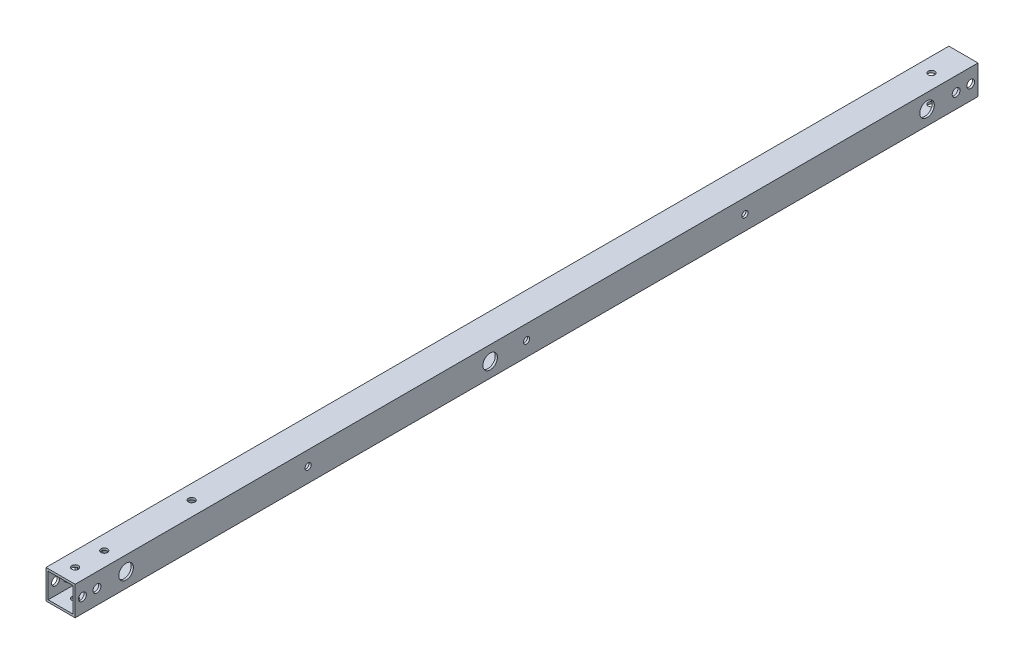
from build123d import *

# Parameters (mm, degrees)
SKETCH_1_W                  = 20
SKETCH_1_H                  = 20
SKETCH_1_W_2                = 17
SKETCH_1_H_2                = 17
EXTRUDE_1_DEPTH             = 620
SKETCH_2_R                  = 2.7
CUT_EXTRUDE_1_DEPTH         = 25
SKETCH_3_R                  = 2.25
CUT_EXTRUDE_2_DEPTH         = 25
SKETCH_4_R                  = 2.7
CUT_EXTRUDE_3_DEPTH         = 40
SKETCH_6_R                  = 5
CUT_EXTRUDE_4_DEPTH         = 10
CUT_EXTRUDE_START           = 10
SKETCH_7_R                  = 5
CUT_EXTRUDE_5_DEPTH         = 20
CUT_EXTRUDE_START_2         = -10
SKETCH_8_R                  = 5
CUT_EXTRUDE_6_DEPTH         = 30
SKETCH_9_R                  = 5
CUT_EXTRUDE_7_DEPTH         = 5
HOLE_WIZARD_4_3_4_3_1_D     = 4.3
HOLE_WIZARD_10_0_10_1_D     = 10
HOLE_WIZARD_10_0_10_1_DEPTH = 1.5


with BuildPart() as part:
    # ｽｹｯﾁ1 → ﾎﾞｽ - 押し出し1 (new body)
    with BuildSketch(Plane.XY):
        Rectangle(SKETCH_1_W, SKETCH_1_H)
        Rectangle(SKETCH_1_W_2, SKETCH_1_H_2, mode=Mode.SUBTRACT)
    extrude(amount=EXTRUDE_1_DEPTH)

    # ｽｹｯﾁ2 → ｶｯﾄ - 押し出し1 (cut)
    with BuildSketch(Plane(origin=(10, 0, 0), x_dir=(0, 0, -1), z_dir=(1, 0, 0))):
        with Locations((-585, 0)):
            Circle(SKETCH_2_R)
        with Locations((-35, 0)):
            Circle(SKETCH_2_R)
        with Locations((-335, 0)):
            Circle(SKETCH_2_R)
    extrude(amount=-CUT_EXTRUDE_1_DEPTH, mode=Mode.SUBTRACT)

    # ｽｹｯﾁ3 → ｶｯﾄ - 押し出し2 (cut)
    with BuildSketch(Plane(origin=(0, 10, 0), x_dir=(1, 0, 0), z_dir=(0, 1, 0))):
        with Locations((0, -22)):
            Circle(SKETCH_3_R)
        with Locations((0, -610)):
            Circle(SKETCH_3_R)
        with Locations((0, -530)):
            Circle(SKETCH_3_R)
        with Locations((0, -590)):
            Circle(SKETCH_3_R)
    extrude(amount=-CUT_EXTRUDE_2_DEPTH, mode=Mode.SUBTRACT)

    # ｽｹｯﾁ4 → ｶｯﾄ - 押し出し3 (cut)
    with BuildSketch(Plane(origin=(10, 0, 0), x_dir=(0, 0, -1), z_dir=(1, 0, 0))):
        with Locations((-15, 0)):
            Circle(SKETCH_4_R)
        with Locations((-5, 0)):
            Circle(SKETCH_4_R)
        with Locations((-615, 0)):
            Circle(SKETCH_4_R)
        with Locations((-605, 0)):
            Circle(SKETCH_4_R)
    extrude(amount=-CUT_EXTRUDE_3_DEPTH, mode=Mode.SUBTRACT)

    # ｽｹｯﾁ6 → ｶｯﾄ - 押し出し4 (cut)
    with BuildSketch(Plane(origin=(0, -10, 0), x_dir=(-1, 0, 0), z_dir=(0, -1, 0))):
        with Locations((0, -530)):
            Circle(SKETCH_6_R)
    extrude(amount=-CUT_EXTRUDE_4_DEPTH, mode=Mode.SUBTRACT)

    # ｽｹｯﾁ7 → ｶｯﾄ - 押し出し5 (cut)
    with BuildSketch(Plane(origin=(-10, 0, 0), x_dir=(0, 0, -1), z_dir=(1, 0, 0)).offset(CUT_EXTRUDE_START)):
        with Locations((-585, 0)):
            Circle(SKETCH_7_R)
        with Locations((-335, 0)):
            Circle(SKETCH_7_R)
        with Locations((-35, 0)):
            Circle(SKETCH_7_R)
    extrude(amount=CUT_EXTRUDE_5_DEPTH, mode=Mode.SUBTRACT)

    # ｽｹｯﾁ8 → ｶｯﾄ - 押し出し6 (cut)
    with BuildSketch(Plane(origin=(10, 0, 0), x_dir=(0, 0, -1), z_dir=(1, 0, 0)).offset(CUT_EXTRUDE_START_2)):
        with Locations((-605, 0)):
            Circle(SKETCH_8_R)
    extrude(amount=-CUT_EXTRUDE_6_DEPTH, mode=Mode.SUBTRACT)

    # ｽｹｯﾁ9 → ｶｯﾄ - 押し出し7 (cut)
    with BuildSketch(Plane.ZY.offset(10)):
        with Locations((15, 0)):
            Circle(SKETCH_9_R)
    extrude(amount=-CUT_EXTRUDE_7_DEPTH, mode=Mode.SUBTRACT)

    # Ø4.3 (4.3) 直径の穴1 (through all)
    with Locations(Plane(origin=(10, 0, 0), x_dir=(0, 0, -1), z_dir=(1, 0, 0))):
        with Locations((-460, 0), (-310, 0), (-160, 0)):
            Hole(HOLE_WIZARD_4_3_4_3_1_D / 2)

    # Ø10.0 (10) 直径の穴1
    with Locations(Plane.ZY.offset(10)):
        with Locations((160, 0), (310, 0), (460, 0)):
            Hole(HOLE_WIZARD_10_0_10_1_D / 2, depth=HOLE_WIZARD_10_0_10_1_DEPTH)


solid = part.part
